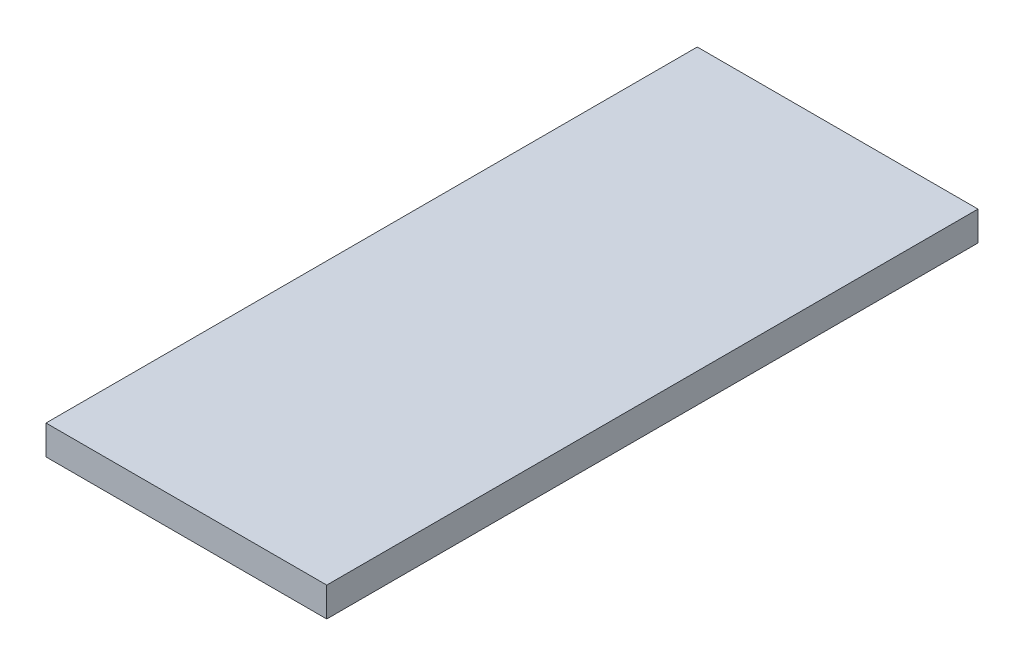
from build123d import *

# Parameters (mm, degrees)
SKETCH1_W           = 24.257
SKETCH1_H           = 56.2737
BOSS_EXTRUDE1_DEPTH = 2.54


with BuildPart() as part:
    # Sketch1 → Boss-Extrude1 (new body)
    with BuildSketch(Plane(origin=(0, 0, 0), x_dir=(1, 0, 0), z_dir=(0, 1, 0))):
        with Locations((12.1285, 28.13685)):
            Rectangle(SKETCH1_W, SKETCH1_H)
    extrude(amount=BOSS_EXTRUDE1_DEPTH)


solid = part.part
